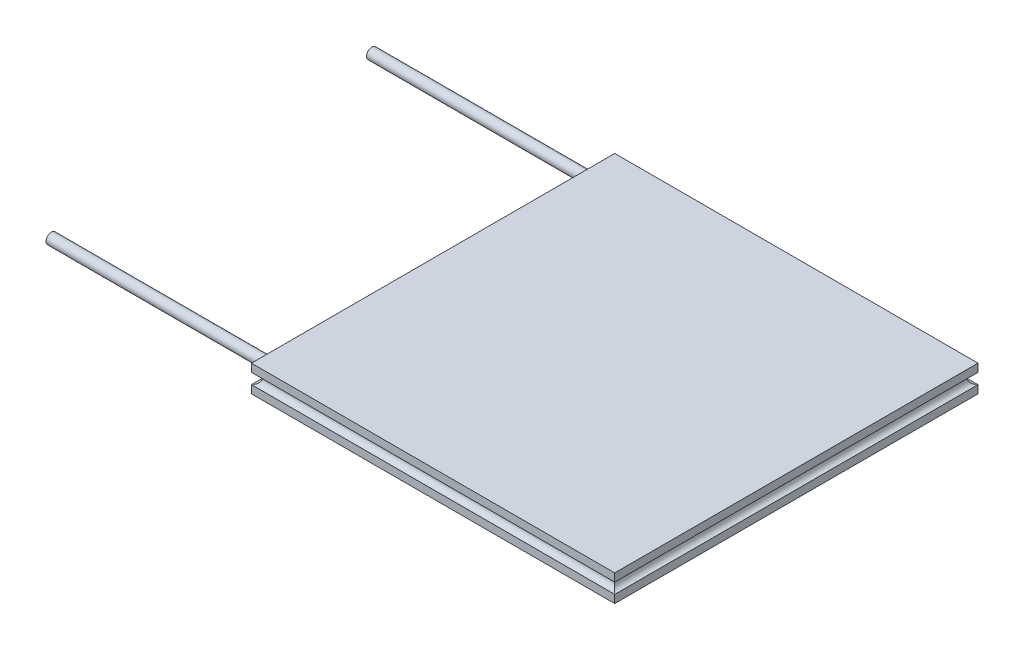
from build123d import *

# Parameters (mm, degrees)
SKETCH2_W                = 41
SKETCH2_H                = 41
BOSS_EXTRUDE1_DEPTH      = 3
SKETCH3_R                = 1
CUT_EXTRUDE1_DEPTH       = 0.2
SKETCH4_R                = 0.6
CUT_EXTRUDE2_DEPTH       = 41
SKETCH5_R                = 0.6
CUT_EXTRUDE3_DEPTH       = 41
SKETCH6_R                = 0.6
BOSS_EXTRUDE2_DEPTH      = 25
BOSS_EXTRUDE2_DEPTH_BACK = 1


with BuildPart() as part:
    # Sketch2 → Boss-Extrude1 (new body)
    with BuildSketch(Plane(origin=(0, 0, 0), x_dir=(1, 0, 0), z_dir=(0, 1, 0))):
        Rectangle(SKETCH2_W, SKETCH2_H)
    extrude(amount=BOSS_EXTRUDE1_DEPTH)

    # Sketch3 → Cut-Extrude1 (cut)
    with BuildSketch(Plane.ZY.offset(20.5)):
        with Locations((-18.087798173, 1.496190707)):
            Circle(SKETCH3_R)
        with Locations((18.087798173, 1.496190707)):
            Circle(SKETCH3_R)
    extrude(amount=-CUT_EXTRUDE1_DEPTH, mode=Mode.SUBTRACT)

    # Sketch4 → Cut-Extrude2 (cut)
    with BuildSketch(Plane.ZY.offset(20.5)):
        with Locations((-20.5, 1.5)):
            Circle(SKETCH4_R)
        with Locations((20.5, 1.5)):
            Circle(SKETCH4_R)
    extrude(amount=-CUT_EXTRUDE2_DEPTH, mode=Mode.SUBTRACT)

    # Sketch5 → Cut-Extrude3 (cut)
    with BuildSketch(Plane.XY.offset(20.5)):
        with Locations((-20.5, 1.5)):
            Circle(SKETCH5_R)
        with Locations((20.5, 1.5)):
            Circle(SKETCH5_R)
    extrude(amount=-CUT_EXTRUDE3_DEPTH, mode=Mode.SUBTRACT)

    # Sketch6 → Boss-Extrude2 (add, two sides)
    with BuildSketch(Plane.ZY.offset(20.5)) as boss_extrude2_sk:
        with Locations((-18.087798173, 1.496190707)):
            Circle(SKETCH6_R)
        with Locations((18.087798173, 1.496190707)):
            Circle(SKETCH6_R)
    extrude(amount=BOSS_EXTRUDE2_DEPTH)
    extrude(boss_extrude2_sk.sketch, amount=-BOSS_EXTRUDE2_DEPTH_BACK)


solid = part.part
